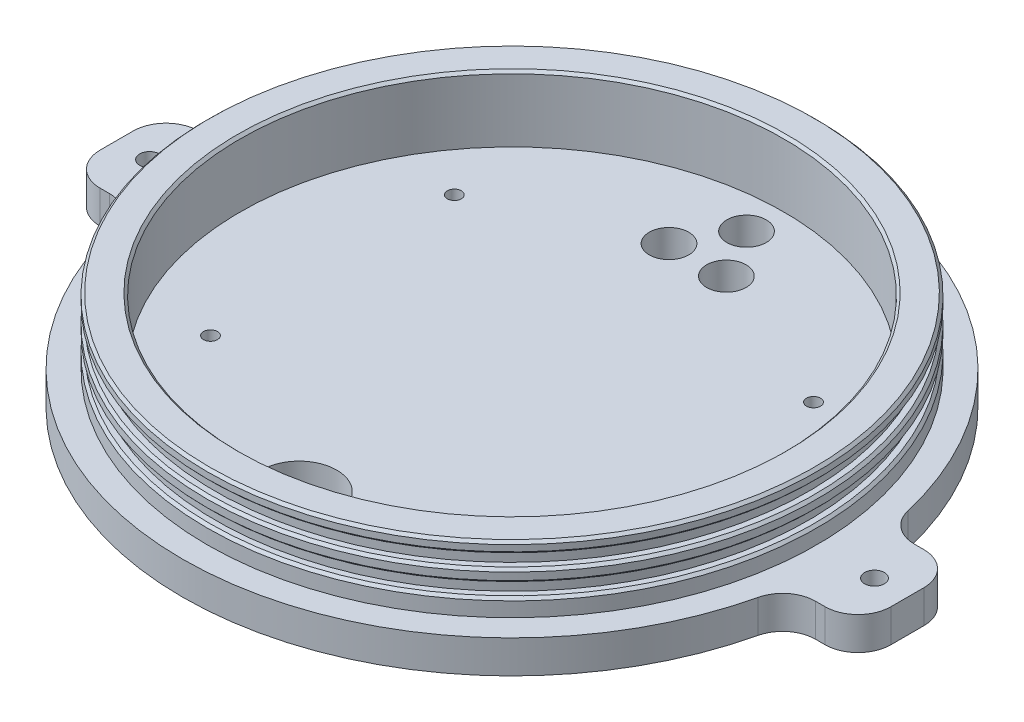
from build123d import *

# Parameters (mm, degrees)
SKETCH1_R                   = 63.5
EXTRUDE1_DEPTH              = 6.35
SKETCH2_R                   = 58.7375
SKETCH2_R_2                 = 52.3875
EXTRUDE2_DEPTH              = 12.7
SKETCH3_W                   = 1.5875
SKETCH3_H                   = 2.38125
CHAMFER1_SIZE               = 0.5
EXTRUDE3_DEPTH              = 6.35
SKETCH4_R                   = 3.799999998
CUT_EXTRUDE1_DEPTH          = 12.7
F_6_CLEARANCE_HOLE1_D       = 3.7973
F_6_CLEARANCE_HOLE1_DEPTH   = 330.2
F_6_CLEARANCE_HOLE1_TIP     = 1.140824014
FILLET1_R                   = 6.35
M14_5_14_5_DIAMETER_HOLE1_D = 14.5
TAP_DRILL_FOR_6_TAP1_D      = 2.7051
TAP_DRILL_FOR_6_TAP1_DEPTH  = 3.302
TAP_DRILL_FOR_6_TAP1_TIP    = 0.81269403


with BuildPart() as part:
    # Sketch1 → Extrude1 (new body)
    with BuildSketch(Plane(origin=(0, 0, 0), x_dir=(1, 0, 0), z_dir=(0, 1, 0))):
        Circle(SKETCH1_R)
    extrude(amount=EXTRUDE1_DEPTH)

    # Sketch2 → Extrude2 (add)
    with BuildSketch(Plane(origin=(0, 6.35, 0), x_dir=(-1, 0, 0), z_dir=(0, 1, 0))):
        Circle(SKETCH2_R)
        Circle(SKETCH2_R_2, mode=Mode.SUBTRACT)
    extrude(amount=EXTRUDE2_DEPTH)

    # Sketch3 → Cut-Revolve1 (revolve, cut)
    with BuildSketch(Plane(origin=(0, 0, 0), x_dir=(0, 0, -1), z_dir=(1, 0, 0))):
        with Locations((-57.94375, 15.656558664)):
            Rectangle(SKETCH3_W, SKETCH3_H)
        with Locations((-57.94375, 10.842416167)):
            Rectangle(SKETCH3_W, SKETCH3_H)
    revolve(axis=Axis((0, 0, 0), (0, 1, 0)), mode=Mode.SUBTRACT)

    # Chamfer1
    chamfer1_edges = [part.edges().sort_by_distance(p)[0] for p in [
        (58.7375, 16.847183664, 0),
        (58.7375, 14.465933664, 0),
        (58.7375, 12.033041167, 0),
        (58.7375, 9.651791167, 0),
        (58.7375, 19.05, 0),
        (52.3875, 19.05, 0),
    ]]
    chamfer(chamfer1_edges, length=CHAMFER1_SIZE)

    # Sketch5 → Extrude3 (add)
    with BuildSketch(Plane.XZ):
        with BuildLine():
            Line((-69.85, 9.525), (69.85, 9.525))
            ThreePointArc((69.85, 9.525), (74.340128061, 7.665128061), (76.2, 3.175))
            Line((76.2, 3.175), (76.2, -3.175))
            ThreePointArc((76.2, -3.175), (74.340128061, -7.665128061), (69.85, -9.525))
            Line((69.85, -9.525), (-69.85, -9.525))
            ThreePointArc((-69.85, -9.525), (-74.340128061, -7.665128061), (-76.2, -3.175))
            Line((-76.2, -3.175), (-76.2, 3.175))
            ThreePointArc((-76.2, 3.175), (-74.340128061, 7.665128061), (-69.85, 9.525))
        make_face()
    extrude(amount=-EXTRUDE3_DEPTH)

    # Sketch4 → Cut-Extrude1 (cut)
    with BuildSketch(Plane.XZ):
        with Locations((-5.783711742, -36.038849572)):
            Circle(SKETCH4_R)
        with Locations((-0.38259163, -45.577892791)):
            Circle(SKETCH4_R)
        with Locations((5.17790207, -36.130863955)):
            Circle(SKETCH4_R)
    extrude(amount=-CUT_EXTRUDE1_DEPTH, mode=Mode.SUBTRACT)

    # #6 Clearance Hole1
    with Locations(Plane(origin=(-69.85, 0, 0), x_dir=(0, 0, -1), z_dir=(0, -1, 0))):
        with Locations((0, 0), (0, 139.7)):
            Hole(F_6_CLEARANCE_HOLE1_D / 2, depth=F_6_CLEARANCE_HOLE1_DEPTH)
            with Locations((0, 0, -(F_6_CLEARANCE_HOLE1_DEPTH + F_6_CLEARANCE_HOLE1_TIP / 2))):  # 118° drill point
                Cone(0, F_6_CLEARANCE_HOLE1_D / 2, F_6_CLEARANCE_HOLE1_TIP, mode=Mode.SUBTRACT)

    # Fillet1
    fillet1_edges = [part.edges().sort_by_distance(p)[0] for p in [
        (62.781560788, 3.175, -9.525),
        (-62.781560788, 3.175, -9.525),
        (-62.781560788, 3.175, 9.525),
        (62.781560788, 3.175, 9.525),
    ]]
    fillet(fillet1_edges, radius=FILLET1_R)

    # M14.5 (14.5) Diameter Hole1 (through all)
    with Locations(Plane(origin=(0, 0, 41.020671835), x_dir=(0, 0, -1), z_dir=(0, -1, 0))):
        with Locations((0, 0)):
            Hole(M14_5_14_5_DIAMETER_HOLE1_D / 2)

    # Tap Drill for #6 Tap1
    with Locations(Plane(origin=(-34.6075, 6.35, -23.495), x_dir=(0, 0, 1), z_dir=(0, 1, 0))):
        with Locations((0, 0), (46.99, 0), (46.99, 69.215), (0, 69.215)):
            Hole(TAP_DRILL_FOR_6_TAP1_D / 2, depth=TAP_DRILL_FOR_6_TAP1_DEPTH)
            with Locations((0, 0, -(TAP_DRILL_FOR_6_TAP1_DEPTH + TAP_DRILL_FOR_6_TAP1_TIP / 2))):  # 118° drill point
                Cone(0, TAP_DRILL_FOR_6_TAP1_D / 2, TAP_DRILL_FOR_6_TAP1_TIP, mode=Mode.SUBTRACT)


solid = part.part
